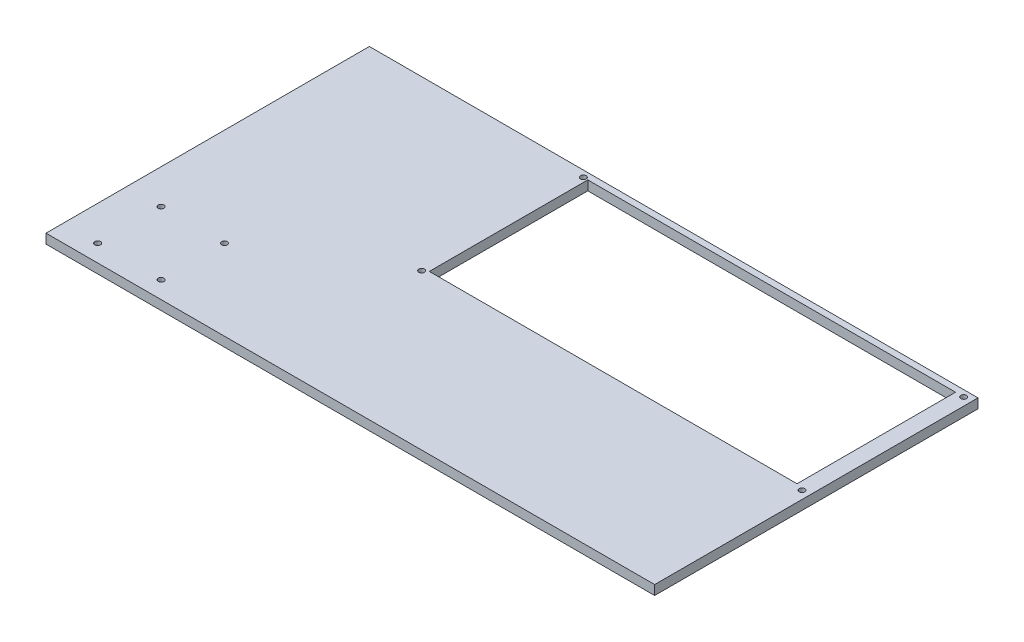
from build123d import *

# Parameters (mm, degrees)
SKETCH1_W               = 960
SKETCH1_H               = 510
BOSS_EXTRUDE1_DEPTH     = 7.5
SKETCH3_W               = 580
SKETCH3_H               = 250
CUT_EXTRUDE1_DEPTH      = 16
ESQUISSE3_R             = 4.5
ENL_V_MAT_EXTRU_2_DEPTH = 16


with BuildPart() as part:
    # Sketch1 → Boss-Extrude1 (new body, symmetric)
    with BuildSketch(Plane(origin=(0, 0, 0), x_dir=(1, 0, 0), z_dir=(0, 1, 0))):
        Rectangle(SKETCH1_W, SKETCH1_H)
    extrude(amount=BOSS_EXTRUDE1_DEPTH, both=True)

    # Sketch3 → Cut-Extrude1 (cut, through all)
    with BuildSketch(Plane(origin=(0, 7.5, 0), x_dir=(1, 0, 0), z_dir=(0, 1, 0))):
        with Locations((164.54751, 120)):
            Rectangle(SKETCH3_W, SKETCH3_H)
    extrude(amount=-CUT_EXTRUDE1_DEPTH, mode=Mode.SUBTRACT)

    # Esquisse3 → Enlèv. mat.-Extru.2 (cut, through all)
    with BuildSketch(Plane.XZ.offset(7.5)):
        with Locations((-425.5, 228)):
            Circle(ESQUISSE3_R)
        with Locations((-425.5, 128)):
            Circle(ESQUISSE3_R)
        with Locations((-325.5, 128)):
            Circle(ESQUISSE3_R)
        with Locations((-325.5, 228)):
            Circle(ESQUISSE3_R)
        with Locations((-132.5, 10)):
            Circle(ESQUISSE3_R)
        with Locations((-132.5, -245)):
            Circle(ESQUISSE3_R)
        with Locations((467.5, -245)):
            Circle(ESQUISSE3_R)
        with Locations((467.5, 10)):
            Circle(ESQUISSE3_R)
    extrude(amount=-ENL_V_MAT_EXTRU_2_DEPTH, mode=Mode.SUBTRACT)


solid = part.part
